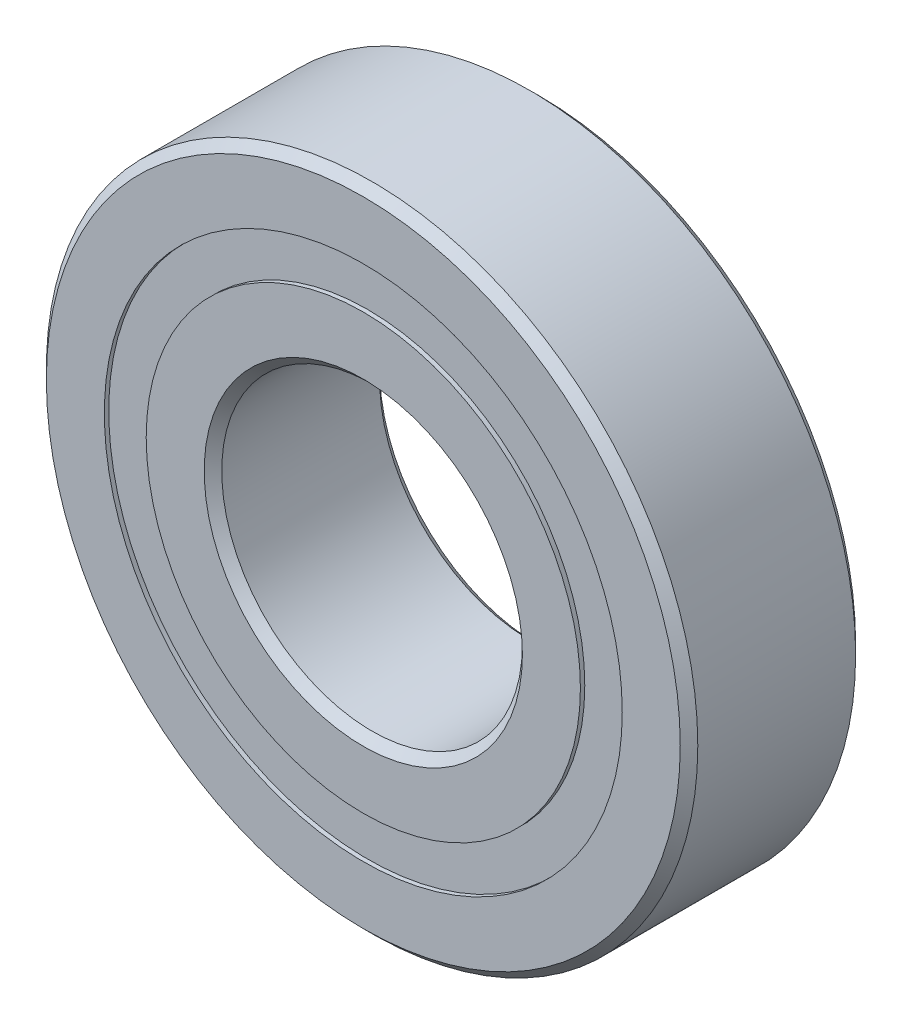
from build123d import *

# Parameters (mm, degrees)
CIRPATTERN1_COUNT = 12
SKETCH5_W         = 2.475587948
SKETCH5_H         = 2.651648352


with BuildPart() as part:
    # Sketch1 → Revolve1 (revolve)
    with BuildSketch(Plane(origin=(0, 0, 0), x_dir=(0, 0, -1), z_dir=(1, 0, 0))):
        with BuildLine():
            Line((5.000625, 20.6375), (-5.000625, 20.6375))
            Line((-5.000625, 20.6375), (-5.55625, 20.081875))
            Line((-5.55625, 20.081875), (-5.55625, 16.407074176))
            Line((-5.55625, 16.407074176), (-2.469444444, 16.407074176))
            ThreePointArc((-2.469444444, 16.407074176), (0, 17.884099552), (2.469444444, 16.407074176))
            Line((2.469444444, 16.407074176), (5.55625, 16.407074176))
            Line((5.55625, 16.407074176), (5.55625, 20.081875))
            Line((5.55625, 20.081875), (5.000625, 20.6375))
        make_face()
    revolve(axis=Axis((0, 0, 5.55625), (0, 0, -1)))


with BuildPart() as body_2:
    # Sketch3 → Revolve3 (revolve)
    with BuildSketch(Plane(origin=(0, 0, 0), x_dir=(0, 0, -1), z_dir=(1, 0, 0))):
        with BuildLine():
            Line((-5.55625, 13.755425824), (-2.469444444, 13.755425824))
            ThreePointArc((-2.469444444, 13.755425824), (0, 12.278400448), (2.469444444, 13.755425824))
            Line((2.469444444, 13.755425824), (5.55625, 13.755425824))
            Line((5.55625, 13.755425824), (5.55625, 10.080625))
            Line((5.55625, 10.080625), (5.000625, 9.525))
            Line((5.000625, 9.525), (-5.000625, 9.525))
            Line((-5.000625, 9.525), (-5.55625, 10.080625))
            Line((-5.55625, 10.080625), (-5.55625, 13.755425824))
        make_face()
    revolve(axis=Axis((0, 0, 5.55625), (0, 0, -1)))


with BuildPart() as body_3:
    # Sketch4 → Revolve4 (revolve)
    with BuildSketch(Plane(origin=(0, 0, 0), x_dir=(0, 0, -1), z_dir=(1, 0, 0))):
        with BuildLine():
            Line((-2.802849552, 15.08125), (2.802849552, 15.08125))
            ThreePointArc((2.802849552, 15.08125), (0, 17.884099552), (-2.802849552, 15.08125))
        make_face()
    revolve(axis=Axis((0, 15.08125, 2.802849552), (0, 0, -1)))


with BuildPart() as cirpattern1_1:
    # CirPattern1: pattern copy
    add(body_3.part.rotate(Axis((0, 0, 0), (0, 0, 1)), 1 * 360 / CIRPATTERN1_COUNT))


with BuildPart() as cirpattern1_2:
    # CirPattern1: pattern copy
    add(body_3.part.rotate(Axis((0, 0, 0), (0, 0, 1)), 2 * 360 / CIRPATTERN1_COUNT))


with BuildPart() as cirpattern1_3:
    # CirPattern1: pattern copy
    add(body_3.part.rotate(Axis((0, 0, 0), (0, 0, 1)), 3 * 360 / CIRPATTERN1_COUNT))


with BuildPart() as cirpattern1_4:
    # CirPattern1: pattern copy
    add(body_3.part.rotate(Axis((0, 0, 0), (0, 0, 1)), 4 * 360 / CIRPATTERN1_COUNT))


with BuildPart() as cirpattern1_5:
    # CirPattern1: pattern copy
    add(body_3.part.rotate(Axis((0, 0, 0), (0, 0, 1)), 5 * 360 / CIRPATTERN1_COUNT))


with BuildPart() as cirpattern1_6:
    # CirPattern1: pattern copy
    add(body_3.part.rotate(Axis((0, 0, 0), (0, 0, 1)), 6 * 360 / CIRPATTERN1_COUNT))


with BuildPart() as cirpattern1_7:
    # CirPattern1: pattern copy
    add(body_3.part.rotate(Axis((0, 0, 0), (0, 0, 1)), 7 * 360 / CIRPATTERN1_COUNT))


with BuildPart() as cirpattern1_8:
    # CirPattern1: pattern copy
    add(body_3.part.rotate(Axis((0, 0, 0), (0, 0, 1)), 8 * 360 / CIRPATTERN1_COUNT))


with BuildPart() as cirpattern1_9:
    # CirPattern1: pattern copy
    add(body_3.part.rotate(Axis((0, 0, 0), (0, 0, 1)), 9 * 360 / CIRPATTERN1_COUNT))


with BuildPart() as cirpattern1_10:
    # CirPattern1: pattern copy
    add(body_3.part.rotate(Axis((0, 0, 0), (0, 0, 1)), 10 * 360 / CIRPATTERN1_COUNT))


with BuildPart() as cirpattern1_11:
    # CirPattern1: pattern copy
    add(body_3.part.rotate(Axis((0, 0, 0), (0, 0, 1)), 11 * 360 / CIRPATTERN1_COUNT))


with BuildPart() as body_15:
    # Sketch5 → Revolve5 (revolve)
    with BuildSketch(Plane(origin=(0, 0, 0), x_dir=(0, 0, -1), z_dir=(1, 0, 0))):
        with Locations((-4.040643526, 15.08125)):
            Rectangle(SKETCH5_W, SKETCH5_H)
        with Locations((4.040643526, 15.08125)):
            Rectangle(SKETCH5_W, SKETCH5_H)
    revolve(axis=Axis((0, 0, 5.55625), (0, 0, -1)))


solid = Compound([part.part, body_2.part, body_3.part, cirpattern1_1.part, cirpattern1_2.part, cirpattern1_3.part, cirpattern1_4.part, cirpattern1_5.part, cirpattern1_6.part, cirpattern1_7.part, cirpattern1_8.part, cirpattern1_9.part, cirpattern1_10.part, cirpattern1_11.part, body_15.part])
